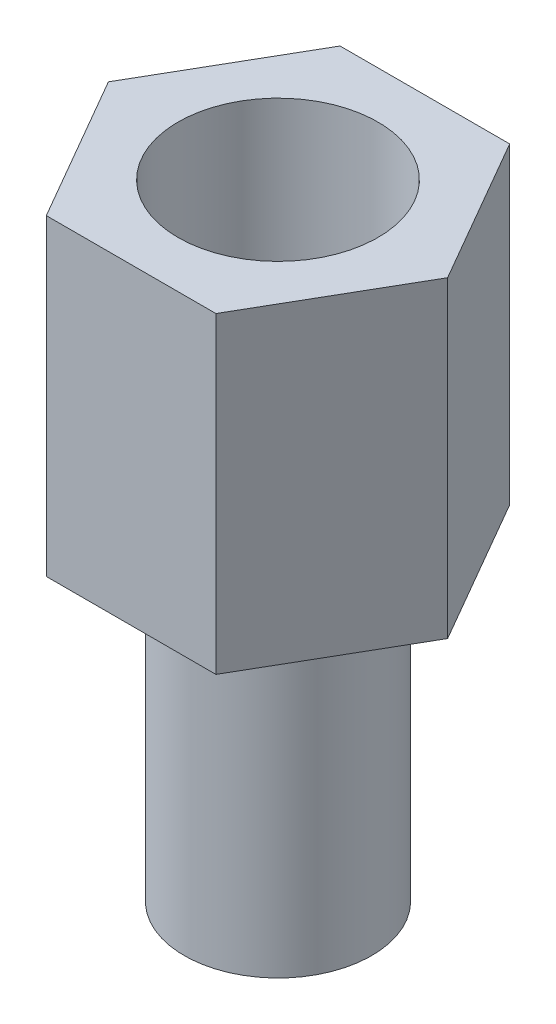
from build123d import *

# Parameters (mm, degrees)
EXTRUDE_1_DEPTH     = 5
SKETCH_2_R          = 1.6
CUT_EXTRUDE_1_DEPTH = 4
SKETCH_3_R          = 1.5
EXTRUDE_2_DEPTH     = 5


with BuildPart() as part:
    # 草图1 → 凸台-拉伸1 (new body)
    with BuildSketch(Plane(origin=(0, 0, 0), x_dir=(1, 0, 0), z_dir=(0, 1, 0))):
        Polygon((2.713546265, 0), (1.356773133, 2.35), (-1.356773133, 2.35), (-2.713546265, 0), (-1.356773133, -2.35), (1.356773133, -2.35), align=None)
    extrude(amount=EXTRUDE_1_DEPTH)

    # 草图2 → 切除-拉伸1 (cut)
    with BuildSketch(Plane(origin=(0, 5, 0), x_dir=(1, 0, 0), z_dir=(0, 1, 0))):
        Circle(SKETCH_2_R)
    extrude(amount=-CUT_EXTRUDE_1_DEPTH, mode=Mode.SUBTRACT)

    # 草图3 → 凸台-拉伸2 (add)
    with BuildSketch(Plane.XZ):
        Circle(SKETCH_3_R)
    extrude(amount=EXTRUDE_2_DEPTH)


solid = part.part
